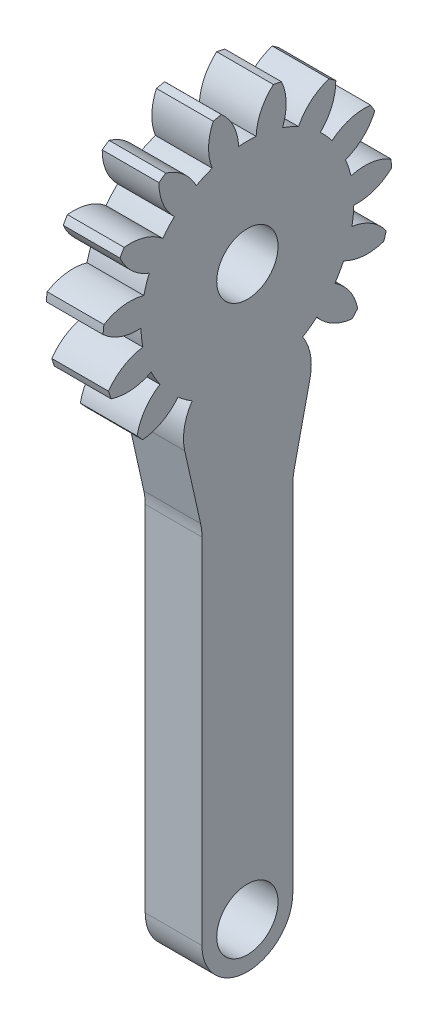
from build123d import *

# Parameters (mm, degrees)
BASPROSKE_W         = 5
BASPROSKE_H         = 12.75
TOOTHCUT_DEPTH      = 19.711627401
TEETHCUTS_COUNT     = 15
TEETHCUTS_ANGLE     = 336
BORSKE_R            = 2.7
BORE_DEPTH          = 50.0049784
SKETCH3_R           = 2.7
BOSS_EXTRUDE2_DEPTH = 5
FILLET1_R           = 5


with BuildPart() as part:
    # BasProSke → Base-Revolve (revolve)
    with BuildSketch(Plane(origin=(0, 0, 0), x_dir=(1, 0, 0), z_dir=(0, 1, 0)), mode=Mode.PRIVATE) as base_revolve_sk:
        with Locations((2.5, 6.375)):
            Rectangle(BASPROSKE_W, BASPROSKE_H)
    revolve(base_revolve_sk.sketch.rotate(Axis((-10, 0, 0), (1, 0, 0)), 180), axis=Axis((-10, 0, 0), (1, 0, 0)))

    # TooCutSke → ToothCut (cut, through all)
    with BuildSketch(Plane(origin=(0, 0, 0), x_dir=(0, 0, -1), z_dir=(1, 0, 0))):
        with BuildLine():
            ThreePointArc((0.769645606, 9.34235097), (0, 9.374), (-0.769645606, 9.34235097))
            ThreePointArc((-0.769645606, 9.34235097), (-1.209019537, 11.113083179), (-2.315283452, 12.563849239))
            ThreePointArc((-2.315283452, 12.563849239), (0, 12.7754), (2.315283452, 12.563849239))
            ThreePointArc((2.315283452, 12.563849239), (1.209019537, 11.113083179), (0.769645606, 9.34235097))
        make_face()
    toothcut = extrude(amount=TOOTHCUT_DEPTH, mode=Mode.SUBTRACT)

    # TeethCuts: ToothCut ×15 about axis
    teethcuts_axis = Axis((-10, 0, 0), (1, 0, 0))
    for i in range(1, TEETHCUTS_COUNT):
        add(toothcut.rotate(teethcuts_axis, i * TEETHCUTS_ANGLE / (TEETHCUTS_COUNT - 1)), mode=Mode.SUBTRACT)

    # BorSke → Bore (cut, symmetric)
    with BuildSketch(Plane(origin=(0, 0, 0), x_dir=(0, 0, -1), z_dir=(1, 0, 0))):
        with Locations(Location((0, 0, 0), (0, 0, 180))):
            Circle(BORSKE_R)
    extrude(amount=BORE_DEPTH, both=True, mode=Mode.SUBTRACT)

    # Sketch3 → Boss-Extrude2 (add)
    with BuildSketch(Plane.ZY):
        with BuildLine():
            Line((-5.518933108, -11.493645085), (-4, -18.283482979))
            Line((-4, -18.283482979), (-4, -50))
            ThreePointArc((-4, -50), (0, -54), (4, -50))
            Line((4, -50), (4, -18.283482979))
            Line((4, -18.283482979), (5.518933108, -11.493645085))
            Line((5.518933108, -11.493645085), (2.695210989, -8.978179867))
            Line((2.695210989, -8.978179867), (-2.695210989, -8.978179867))
            Line((-2.695210989, -8.978179867), (-5.518933108, -11.493645085))
        make_face()
        with Locations((0, -50)):
            Circle(SKETCH3_R, mode=Mode.SUBTRACT)
    extrude(amount=-BOSS_EXTRUDE2_DEPTH)

    # Fillet1
    fillet1_edges = [part.edges().sort_by_distance(p)[0] for p in [
        (2.5, -18.283482979, -4),
        (2.5, -18.283482979, 4),
    ]]
    fillet(fillet1_edges, radius=FILLET1_R)


solid = part.part
